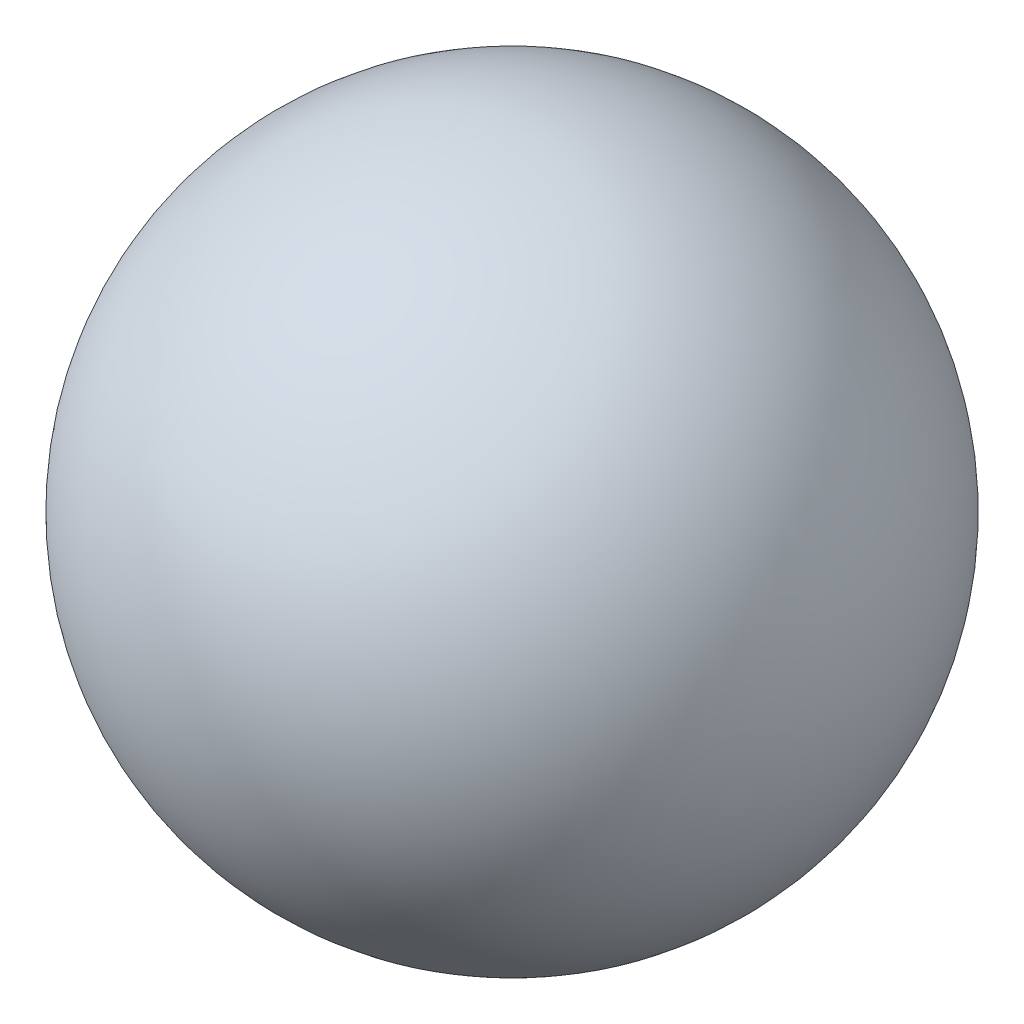
from build123d import *


with BuildPart() as part:
    # Sketch2 → Revolve1 (revolve)
    with BuildSketch(Plane.XY):
        with BuildLine():
            Line((0, 150), (0, -150))
            ThreePointArc((0, -150), (150, 0), (0, 150))
        make_face()
    revolve(axis=Axis((0, 150, 0), (0, -1, 0)))


solid = part.part
